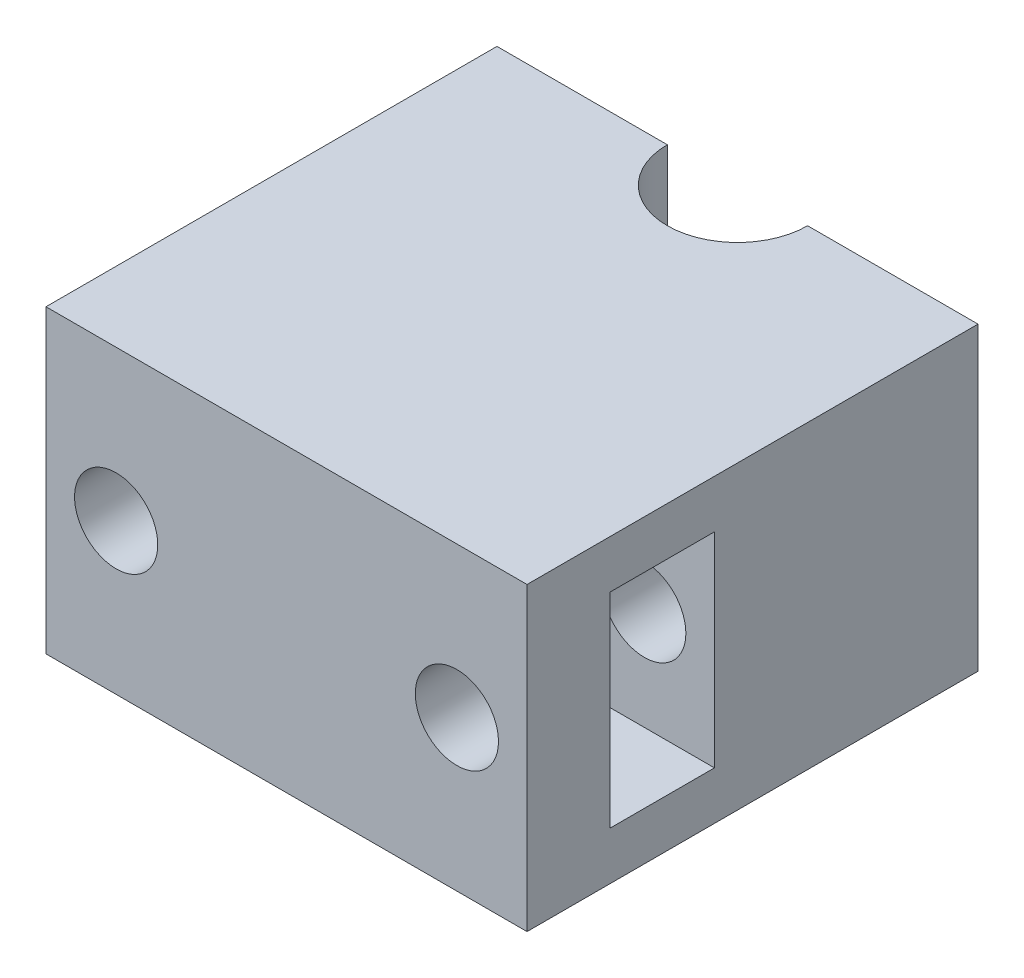
from build123d import *

# Parameters (mm, degrees)
SKETCH1_W               = 48
SKETCH1_H               = 45
BOSS_EXTRUDE1_DEPTH     = 30
SKETCH2_W               = 10.4
SKETCH2_H               = 20.4
CUT_EXTRUDE1_DEPTH      = 49
SKETCH3_R               = 4.15
CUT_EXTRUDE2_DEPTH      = 46
CUT_EXTRUDE3_DEPTH      = 1
CUT_EXTRUDE3_DEPTH_BACK = 31


with BuildPart() as part:
    # Sketch1 → Boss-Extrude1 (new body)
    with BuildSketch(Plane(origin=(0, 0, 0), x_dir=(1, 0, 0), z_dir=(0, 1, 0))):
        Rectangle(SKETCH1_W, SKETCH1_H)
    extrude(amount=BOSS_EXTRUDE1_DEPTH)

    # Sketch2 → Cut-Extrude1 (cut, through all)
    with BuildSketch(Plane(origin=(24, 0, 0), x_dir=(0, 0, -1), z_dir=(1, 0, 0))):
        with Locations((-9, 15)):
            Rectangle(SKETCH2_W, SKETCH2_H)
    extrude(amount=-CUT_EXTRUDE1_DEPTH, mode=Mode.SUBTRACT)

    # Sketch3 → Cut-Extrude2 (cut, through all)
    with BuildSketch(Plane.XY.offset(22.5)):
        with Locations((-17, 15)):
            Circle(SKETCH3_R)
        with Locations((17, 15)):
            Circle(SKETCH3_R)
    extrude(amount=-CUT_EXTRUDE2_DEPTH, mode=Mode.SUBTRACT)

    # Sketch4 → Cut-Extrude3 (cut, two sides)
    with BuildSketch(Plane(origin=(0, 30, 0), x_dir=(1, 0, 0), z_dir=(0, 1, 0))) as cut_extrude3_sk:
        with BuildLine():
            Line((-7, 141.788608739), (-7, 22.5))
            ThreePointArc((-7, 22.5), (0, 15.5), (7, 22.5))
            Line((7, 22.5), (7, 141.788608739))
            Line((7, 141.788608739), (7, 380.365826216))
            Line((7, 380.365826216), (-7, 380.365826216))
            Line((-7, 380.365826216), (-7, 141.788608739))
        make_face()
    extrude(amount=CUT_EXTRUDE3_DEPTH, mode=Mode.SUBTRACT)
    extrude(cut_extrude3_sk.sketch, amount=-CUT_EXTRUDE3_DEPTH_BACK, mode=Mode.SUBTRACT)


solid = part.part
